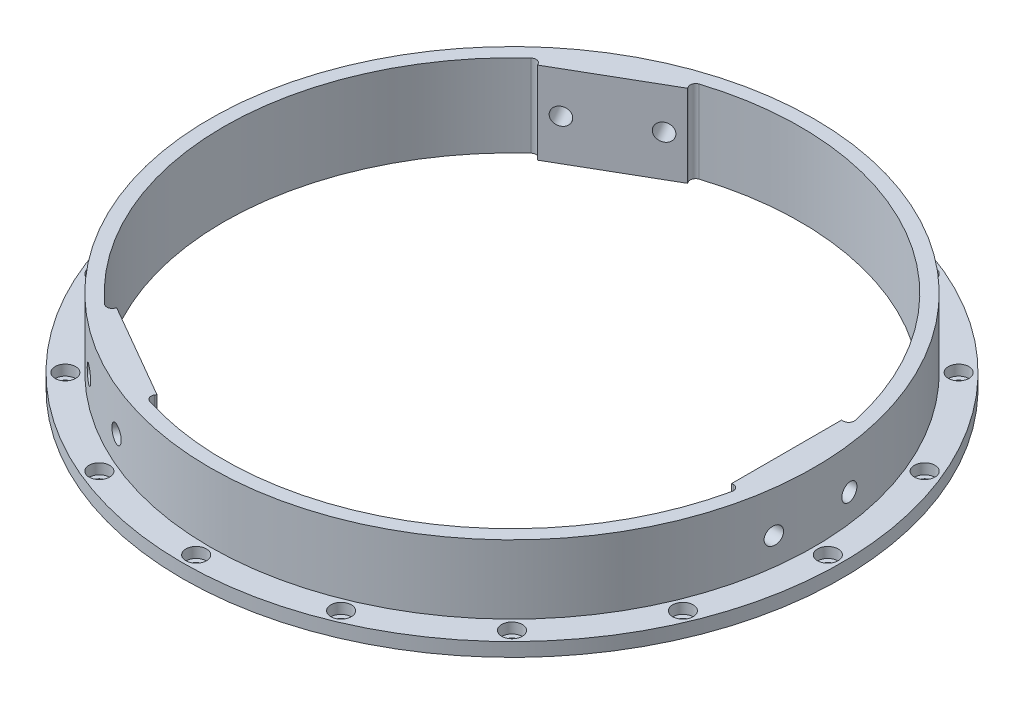
from build123d import *

# Parameters (mm, degrees)
SKETCH1_R                = 152.4
SKETCH1_R_2              = 133.35
BOSS_EXTRUDE1_DEPTH      = 38.1
SKETCH2_R                = 152.4
SKETCH2_R_2              = 139.7
CUT_EXTRUDE1_DEPTH       = 31.75
BOSS_EXTRUDE2_DEPTH      = 38.1
FILLET1_R                = 2.54
HOLE1_D                  = 8
HOLE1_DEPTH              = 81.182271537
CIRPATTERN1_COUNT        = 3
FILLET1_OF_CIRPATTERN1_R = 2.54
CIRPATTERN2_COUNT        = 16


with BuildPart() as part:
    # Sketch1 → Boss-Extrude1 (new body)
    with BuildSketch(Plane(origin=(0, 0, 0), x_dir=(1, 0, 0), z_dir=(0, 1, 0))):
        Circle(SKETCH1_R)
        Circle(SKETCH1_R_2, mode=Mode.SUBTRACT)
    extrude(amount=BOSS_EXTRUDE1_DEPTH)

    # Sketch2 → Cut-Extrude1 (cut)
    with BuildSketch(Plane(origin=(0, 38.1, 0), x_dir=(1, 0, 0), z_dir=(0, 1, 0))):
        Circle(SKETCH2_R)
        Circle(SKETCH2_R_2, mode=Mode.SUBTRACT)
    extrude(amount=-CUT_EXTRUDE1_DEPTH, mode=Mode.SUBTRACT)

    # Sketch3 → Boss-Extrude2 (add, through all)
    with BuildSketch(Plane(origin=(0, 38.1, 0), x_dir=(1, 0, 0), z_dir=(0, 1, 0))):
        with BuildLine():
            Line((127, 25.4), (127, -25.4))
            Line((127, -25.4), (130.908603613, -25.4))
            ThreePointArc((130.908603613, -25.4), (133.35, 0), (130.908603613, 25.4))
            Line((130.908603613, 25.4), (127, 25.4))
        make_face()
    boss_extrude2 = extrude(amount=-BOSS_EXTRUDE2_DEPTH)

    # Fillet1
    fillet1_edges = [part.edges().sort_by_distance(p)[0] for p in [
        (130.908603613, 19.05, -25.4),
        (130.908603613, 19.05, 25.4),
    ]]
    fillet(fillet1_edges, radius=FILLET1_R)

    # Hole1
    with Locations(Plane(origin=(127, 0, -417.943859866), x_dir=(0, 0, 1), z_dir=(-1, 0, 0))):
        with Locations((400.481359866, 19.05), (435.406359866, 19.05)):
            hole1 = Hole(HOLE1_D / 2, depth=HOLE1_DEPTH)

    # CirPattern1: Boss-Extrude2, Hole1 ×3 about axis
    cirpattern1_axis = Axis((0, 0, 0), (0, 1, 0))
    for i in range(1, CIRPATTERN1_COUNT):
        add(boss_extrude2.rotate(cirpattern1_axis, i * 360 / CIRPATTERN1_COUNT))
        add(hole1.rotate(cirpattern1_axis, i * 360 / CIRPATTERN1_COUNT), mode=Mode.SUBTRACT)

    # Fillet1 of CirPattern1
    fillet1_of_cirpattern1_edges = [part.edges().sort_by_distance(p)[0] for p in [
        (-87.451347063, 19.05, -100.670176303),
        (-43.457256551, 19.05, -126.070176303),
        (-43.457256551, 19.05, 126.070176303),
        (-87.451347063, 19.05, 100.670176303),
    ]]
    fillet(fillet1_of_cirpattern1_edges, radius=FILLET1_OF_CIRPATTERN1_R)

    # Sketch8 → CBORE for #10 Socket Head Cap Screw1 (revolve, cut)
    with BuildSketch(Plane(origin=(146.05, 6.35, 0), x_dir=(0, 0, 1), z_dir=(1, 0, 0))):
        Polygon((0, 0), (0, 9.407816902), (2.5527, 7.874), (2.5527, 4.826), (4.7625, 4.826), (4.7625, 0), align=None)
    cbore_for_10_socket_head_cap_screw1 = revolve(axis=Axis((146.05, 12.7, 0), (0, -1, 0)), mode=Mode.SUBTRACT)

    # CirPattern2: CBORE for #10 Socket Head Cap Screw1 ×16 about axis
    cirpattern2_axis = Axis((0, 0, 0), (0, 1, 0))
    for i in range(1, CIRPATTERN2_COUNT):
        add(cbore_for_10_socket_head_cap_screw1.rotate(cirpattern2_axis, i * 360 / CIRPATTERN2_COUNT), mode=Mode.SUBTRACT)


solid = part.part
